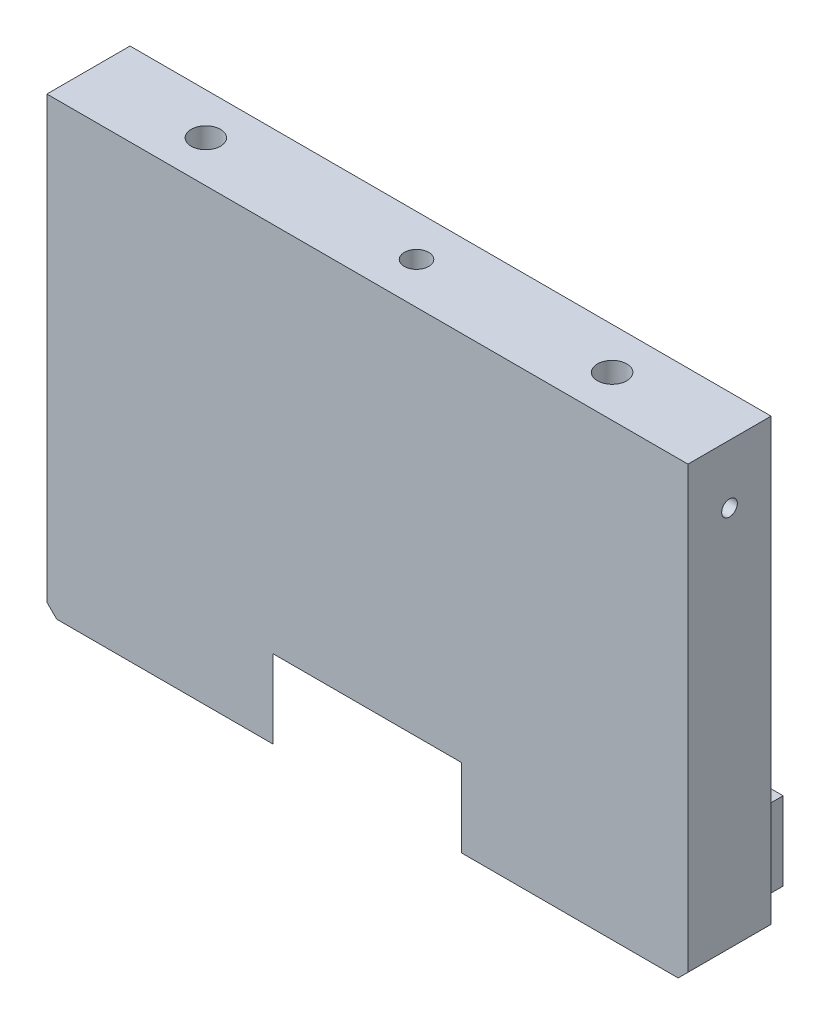
from build123d import *

# Parameters (mm, degrees)
SKETCH1_W                 = 65.54
SKETCH1_H                 = 46
BOSS_EXTRUDE1_DEPTH       = 3.5
SKETCH2_W                 = 58
SKETCH2_H                 = 8
BOSS_EXTRUDE2_DEPTH       = 10
CUT_EXTRUDE1_DEPTH        = 8
BOSS_EXTRUDE3_DEPTH       = 5
CHAMFER1_SIZE             = 1
F_3_0MM_DOWEL_HOLE1_D     = 3
F_3_0MM_DOWEL_HOLE1_DEPTH = 4.5
F_3_0MM_DOWEL_HOLE1_TIP   = 0.901290929
M3X0_5_TAPPED_HOLE1_D     = 2.5
M3X0_5_TAPPED_HOLE1_DEPTH = 7.5
M3X0_5_TAPPED_HOLE1_TIP   = 0.751075774
M2X0_4_TAPPED_HOLE1_D     = 1.6
M2X0_4_TAPPED_HOLE1_DEPTH = 5.2
M2X0_4_TAPPED_HOLE1_TIP   = 0.480688495
M2X0_4_TAPPED_HOLE2_D     = 1.6
M2X0_4_TAPPED_HOLE2_DEPTH = 5.2
M2X0_4_TAPPED_HOLE2_TIP   = 0.480688495


with BuildPart() as part:
    # Sketch1 → Boss-Extrude1 (new body)
    with BuildSketch(Plane.XY):
        Rectangle(SKETCH1_W, SKETCH1_H)
    extrude(amount=BOSS_EXTRUDE1_DEPTH)

    # Sketch2 → Boss-Extrude2 (add)
    with BuildSketch(Plane(origin=(0, 0, 0), x_dir=(-1, 0, 0), z_dir=(0, 0, -1))):
        with Locations((0, -19)):
            Rectangle(SKETCH2_W, SKETCH2_H)
    extrude(amount=BOSS_EXTRUDE2_DEPTH)

    # Sketch5 → Cut-Extrude1 (cut)
    with BuildSketch(Plane.XZ.offset(23)):
        with BuildLine():
            Line((-26.311212976, -10.5), (26.311212976, -10.5))
            ThreePointArc((26.311212976, -10.5), (19.200628572, -1.861773381), (9.41946352, 3.570369836))
            Line((9.41946352, 3.570369836), (9.41946352, 4))
            Line((9.41946352, 4), (-9.622947545, 4))
            Line((-9.622947545, 4), (-9.622947545, 3.502268118))
            ThreePointArc((-9.622947545, 3.502268118), (-19.282941975, -1.930587904), (-26.311212976, -10.5))
        make_face()
    extrude(amount=-CUT_EXTRUDE1_DEPTH, mode=Mode.SUBTRACT)

    # Sketch6 → Boss-Extrude3 (add)
    with BuildSketch(Plane(origin=(0, 0, 0), x_dir=(-1, 0, 0), z_dir=(0, 0, -1))):
        Polygon((-32.77, 23), (-32.77, -23), (-29, -23), (-29, -15), (29, -15), (29, -23), (32.77, -23), (32.77, 23), align=None)
    extrude(amount=BOSS_EXTRUDE3_DEPTH)

    # Chamfer1
    chamfer1_edges = [part.edges().sort_by_distance(p)[0] for p in [
        (32.77, -23, -0.75),
        (-32.77, -23, -0.75),
    ]]
    chamfer(chamfer1_edges, length=CHAMFER1_SIZE)

    # Ø3.0mm Dowel Hole1
    with Locations(Plane(origin=(0, 23, 0), x_dir=(1, 0, 0), z_dir=(0, 1, 0))):
        with Locations((-20.77, 0.75), (20.77, 0.75)):
            Hole(F_3_0MM_DOWEL_HOLE1_D / 2, depth=F_3_0MM_DOWEL_HOLE1_DEPTH)
            with Locations((0, 0, -(F_3_0MM_DOWEL_HOLE1_DEPTH + F_3_0MM_DOWEL_HOLE1_TIP / 2))):  # 118° drill point
                Cone(0, F_3_0MM_DOWEL_HOLE1_D / 2, F_3_0MM_DOWEL_HOLE1_TIP, mode=Mode.SUBTRACT)

    # M3x0.5 Tapped Hole1
    with Locations(Plane(origin=(0, 23, 0), x_dir=(1, 0, 0), z_dir=(0, 1, 0))):
        with Locations((0.77, 0.75)):
            Hole(M3X0_5_TAPPED_HOLE1_D / 2, depth=M3X0_5_TAPPED_HOLE1_DEPTH)
            with Locations((0, 0, -(M3X0_5_TAPPED_HOLE1_DEPTH + M3X0_5_TAPPED_HOLE1_TIP / 2))):  # 118° drill point
                Cone(0, M3X0_5_TAPPED_HOLE1_D / 2, M3X0_5_TAPPED_HOLE1_TIP, mode=Mode.SUBTRACT)

    # M2x0.4 Tapped Hole1
    with Locations(Plane(origin=(0, -23, 0), x_dir=(-1, 0, 0), z_dir=(0, -1, 0))):
        with Locations((28.0334, 0.5)):
            Hole(M2X0_4_TAPPED_HOLE1_D / 2, depth=M2X0_4_TAPPED_HOLE1_DEPTH)
            with Locations((0, 0, -(M2X0_4_TAPPED_HOLE1_DEPTH + M2X0_4_TAPPED_HOLE1_TIP / 2))):  # 118° drill point
                Cone(0, M2X0_4_TAPPED_HOLE1_D / 2, M2X0_4_TAPPED_HOLE1_TIP, mode=Mode.SUBTRACT)

    # M2x0.4 Tapped Hole2
    with Locations(Plane(origin=(32.77, 0, 0), x_dir=(0, 0, -1), z_dir=(1, 0, 0))):
        with Locations((0.75, 17)):
            Hole(M2X0_4_TAPPED_HOLE2_D / 2, depth=M2X0_4_TAPPED_HOLE2_DEPTH)
            with Locations((0, 0, -(M2X0_4_TAPPED_HOLE2_DEPTH + M2X0_4_TAPPED_HOLE2_TIP / 2))):  # 118° drill point
                Cone(0, M2X0_4_TAPPED_HOLE2_D / 2, M2X0_4_TAPPED_HOLE2_TIP, mode=Mode.SUBTRACT)


solid = part.part
